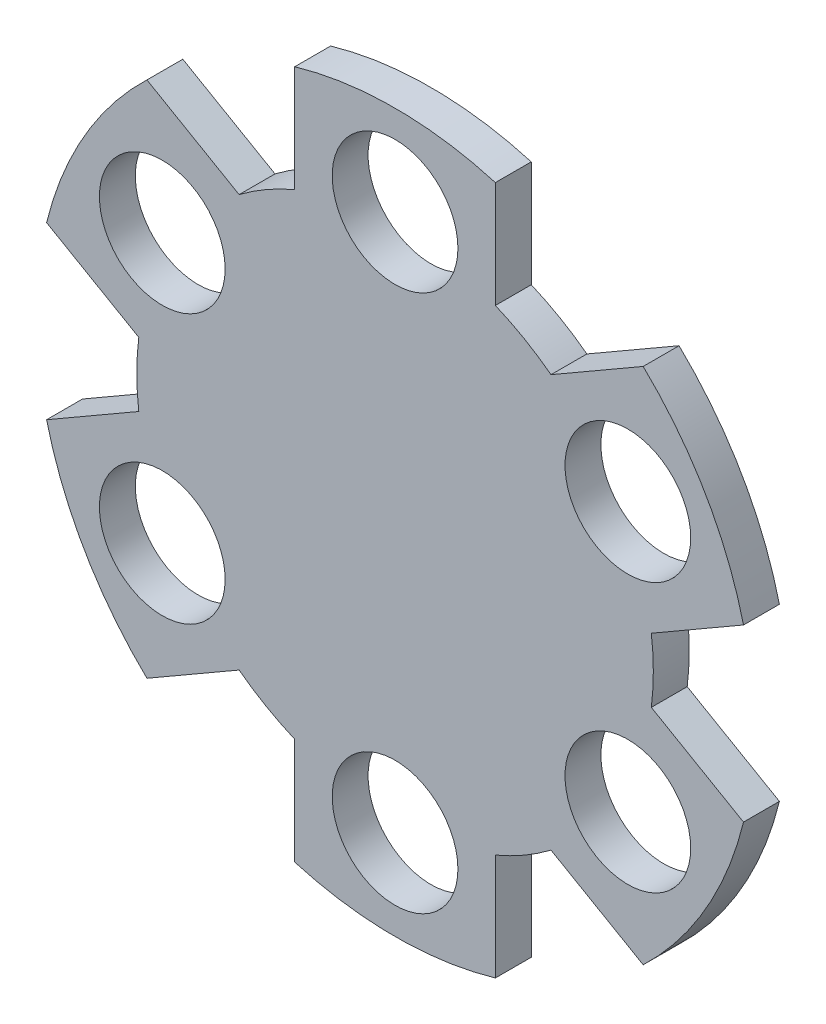
from build123d import *

# Parameters (mm, degrees)
SKETCH1_R          = 31.75
SKETCH1_R_2        = 5.5626
EXTRUDE1_DEPTH     = 3.175
CUT_EXTRUDE1_DEPTH = 4.175


with BuildPart() as part:
    # Sketch1 → Extrude1 (new body)
    with BuildSketch(Plane.XY):
        Circle(SKETCH1_R)
        with Locations((0, 23.78973844)):
            Circle(SKETCH1_R_2, mode=Mode.SUBTRACT)
        with Locations((20.602517839, 11.89486922)):
            Circle(SKETCH1_R_2, mode=Mode.SUBTRACT)
        with Locations((20.602517839, -11.89486922)):
            Circle(SKETCH1_R_2, mode=Mode.SUBTRACT)
        with Locations((0, -23.78973844)):
            Circle(SKETCH1_R_2, mode=Mode.SUBTRACT)
        with Locations((-20.602517839, -11.89486922)):
            Circle(SKETCH1_R_2, mode=Mode.SUBTRACT)
        with Locations((-20.602517839, 11.89486922)):
            Circle(SKETCH1_R_2, mode=Mode.SUBTRACT)
    extrude(amount=EXTRUDE1_DEPTH)

    # Sketch2 → Cut-Extrude1 (cut, through all)
    with BuildSketch(Plane(origin=(0, 0, 0), x_dir=(-1, 0, 0), z_dir=(0, 0, -1))):
        with BuildLine():
            Line((8.878771943, 21.061731462), (8.878771943, 30.483272606))
            ThreePointArc((8.878771943, 30.483272606), (15.875, 27.49630657), (21.959902496, 22.93087836))
            Line((21.959902496, 22.93087836), (13.800608523, 18.220107788))
            ThreePointArc((13.800608523, 18.220107788), (11.42835425, 19.794490207), (8.878771943, 21.061731462))
        make_face()
        with BuildLine():
            Line((-8.878771943, 30.483272606), (-8.878771943, 21.061731462))
            ThreePointArc((-8.878771943, 21.061731462), (-11.42835425, 19.794490207), (-13.800608523, 18.220107788))
            Line((-13.800608523, 18.220107788), (-21.959902496, 22.93087836))
            ThreePointArc((-21.959902496, 22.93087836), (-15.875, 27.49630657), (-8.878771943, 30.483272606))
        make_face()
        with BuildLine():
            Line((22.679380466, 2.841623674), (30.838674439, 7.552394246))
            ThreePointArc((30.838674439, 7.552394246), (31.75, 0), (30.838674439, -7.552394246))
            Line((30.838674439, -7.552394246), (22.679380466, -2.841623674))
            ThreePointArc((22.679380466, -2.841623674), (22.856708499, 0), (22.679380466, 2.841623674))
        make_face()
        with BuildLine():
            Line((13.800608523, -18.220107788), (21.959902496, -22.93087836))
            ThreePointArc((21.959902496, -22.93087836), (15.875, -27.49630657), (8.878771943, -30.483272606))
            Line((8.878771943, -30.483272606), (8.878771943, -21.061731462))
            ThreePointArc((8.878771943, -21.061731462), (11.42835425, -19.794490207), (13.800608523, -18.220107788))
        make_face()
        with BuildLine():
            Line((-8.878771943, -21.061731462), (-8.878771943, -30.483272606))
            ThreePointArc((-8.878771943, -30.483272606), (-15.875, -27.49630657), (-21.959902496, -22.93087836))
            Line((-21.959902496, -22.93087836), (-13.800608523, -18.220107788))
            ThreePointArc((-13.800608523, -18.220107788), (-11.42835425, -19.794490207), (-8.878771943, -21.061731462))
        make_face()
        with BuildLine():
            Line((-22.679380466, -2.841623674), (-30.838674439, -7.552394246))
            ThreePointArc((-30.838674439, -7.552394246), (-31.75, 0), (-30.838674439, 7.552394246))
            Line((-30.838674439, 7.552394246), (-22.679380466, 2.841623674))
            ThreePointArc((-22.679380466, 2.841623674), (-22.856708499, 0), (-22.679380466, -2.841623674))
        make_face()
    extrude(amount=-CUT_EXTRUDE1_DEPTH, mode=Mode.SUBTRACT)


solid = part.part
